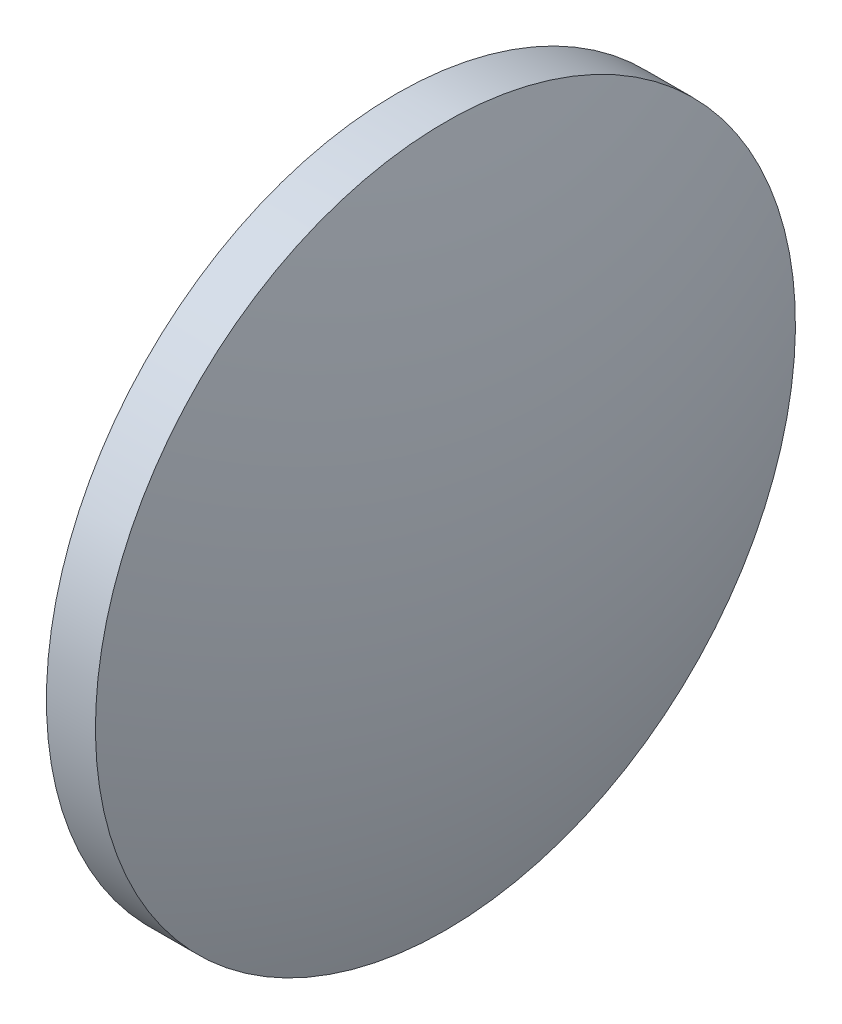
from build123d import *

# Parameters (mm, degrees)
SKETCH_1_ONE_SIDE_W = 0.9
SKETCH_1_ONE_SIDE_H = 6.425004896


with BuildPart() as part:
    # 草图1 one side → 旋转1 (revolve)
    with BuildSketch(Plane.XY, mode=Mode.PRIVATE) as revolve_1_sk:
        with Locations((43.739710097, 27.807680728)):
            Rectangle(SKETCH_1_ONE_SIDE_W, SKETCH_1_ONE_SIDE_H)
        with BuildLine():
            Line((42.239709179, 24.59517828), (43.289710097, 24.59517828))
            Line((43.289710097, 24.59517828), (43.289710097, 31.020183176))
            ThreePointArc((43.289710097, 31.020183176), (42.503939066, 27.850296935), (42.239709179, 24.59517828))
        make_face()
        with BuildLine():
            Line((44.189710097, 24.59517828), (45.239711015, 24.59517828))
            ThreePointArc((45.239711015, 24.59517828), (44.975481129, 27.850296935), (44.189710097, 31.020183176))
            Line((44.189710097, 31.020183176), (44.189710097, 24.59517828))
        make_face()
    revolve(revolve_1_sk.sketch.rotate(Axis((41.055149458, 24.59517828, 0), (1, 0, 0)), 180), axis=Axis((41.055149458, 24.59517828, 0), (1, 0, 0)))  # turned: the seam where the file's is


solid = part.part
